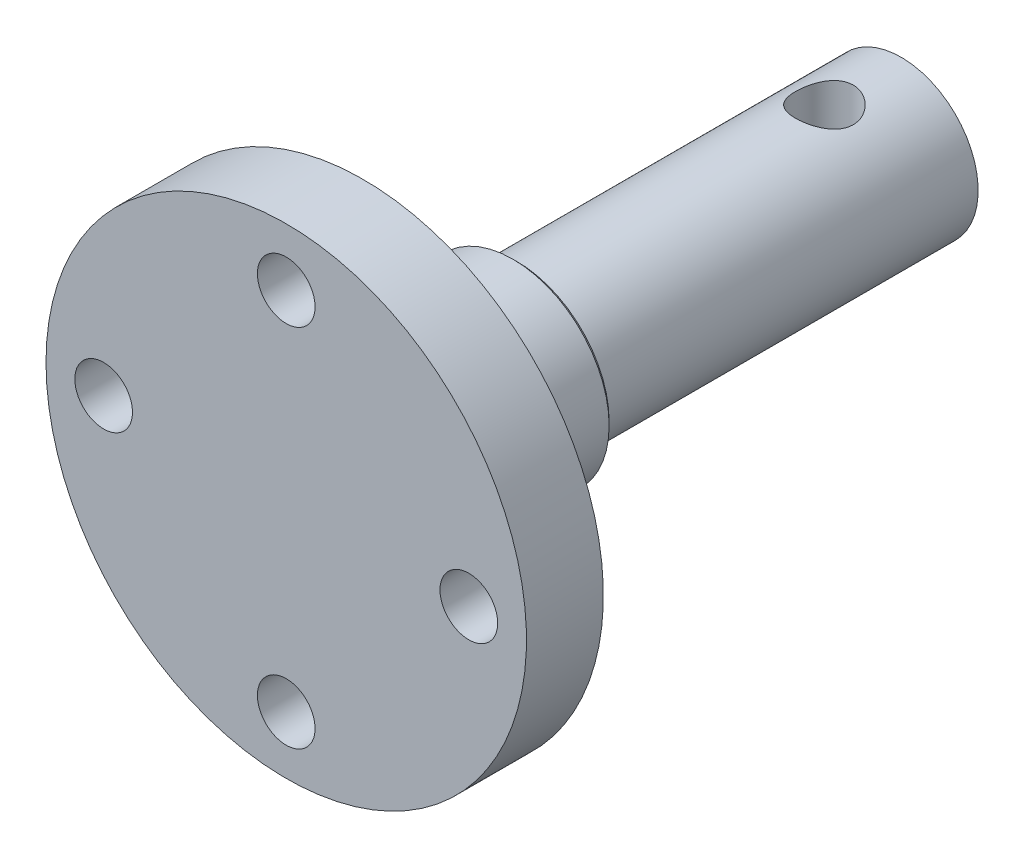
from build123d import *

# Parameters (mm, degrees)
SKETCH7_R               = 1.5
CUT_EXTRUDE1_DEPTH      = 5
CHAMFER1_SIZE           = 0.2
SKETCH4_R               = 1.5
CUT_EXTRUDE2_DEPTH      = 13.5
CUT_EXTRUDE2_DEPTH_BACK = 13.5


with BuildPart() as part:
    # Sketch1 → Revolve1 (revolve)
    with BuildSketch(Plane(origin=(0, 0, 0), x_dir=(1, 0, 0), z_dir=(0, 1, 0))):
        Polygon((0, 0), (0, 32), (4, 32), (4, 12), (5, 12), (5, 4), (12.5, 4), (12.5, 0), align=None)
    revolve(axis=Axis((0, 0, 0), (0, 0, 1)))

    # Sketch7 → Cut-Extrude1 (cut, through all)
    with BuildSketch(Plane(origin=(0, 0, -4), x_dir=(-1, 0, 0), z_dir=(0, 0, -1))):
        with Locations((-9.5, 0)):
            Circle(SKETCH7_R)
        with Locations((0, 9.5)):
            Circle(SKETCH7_R)
        with Locations((9.5, 0)):
            Circle(SKETCH7_R)
        with Locations((0, -9.5)):
            Circle(SKETCH7_R)
    extrude(amount=-CUT_EXTRUDE1_DEPTH, mode=Mode.SUBTRACT)

    # Chamfer1
    chamfer1_edges = [part.edges().sort_by_distance(p)[0] for p in [
        (-5, 0, -12),
    ]]
    chamfer(chamfer1_edges, length=CHAMFER1_SIZE)

    # Sketch4 → Cut-Extrude2 (cut, two sides)
    with BuildSketch(Plane(origin=(0, 0, 0), x_dir=(1, 0, 0), z_dir=(0, 1, 0))) as cut_extrude2_sk:
        with Locations((0, 28)):
            Circle(SKETCH4_R)
    extrude(amount=CUT_EXTRUDE2_DEPTH, mode=Mode.SUBTRACT)
    extrude(cut_extrude2_sk.sketch, amount=-CUT_EXTRUDE2_DEPTH_BACK, mode=Mode.SUBTRACT)


solid = part.part
